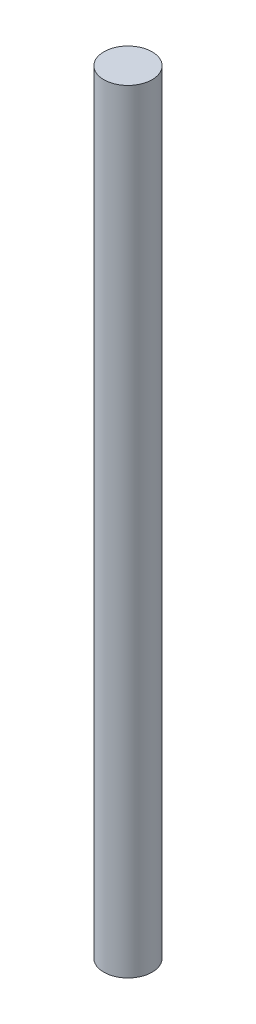
from build123d import *

# Parameters (mm, degrees)
SKETCH1_R           = 4.7625
BOSS_EXTRUDE1_DEPTH = 152.4


with BuildPart() as part:
    # Sketch1 → Boss-Extrude1 (new body)
    with BuildSketch(Plane(origin=(0, 0, 0), x_dir=(1, 0, 0), z_dir=(0, 1, 0))):
        Circle(SKETCH1_R)
    extrude(amount=BOSS_EXTRUDE1_DEPTH)


solid = part.part
